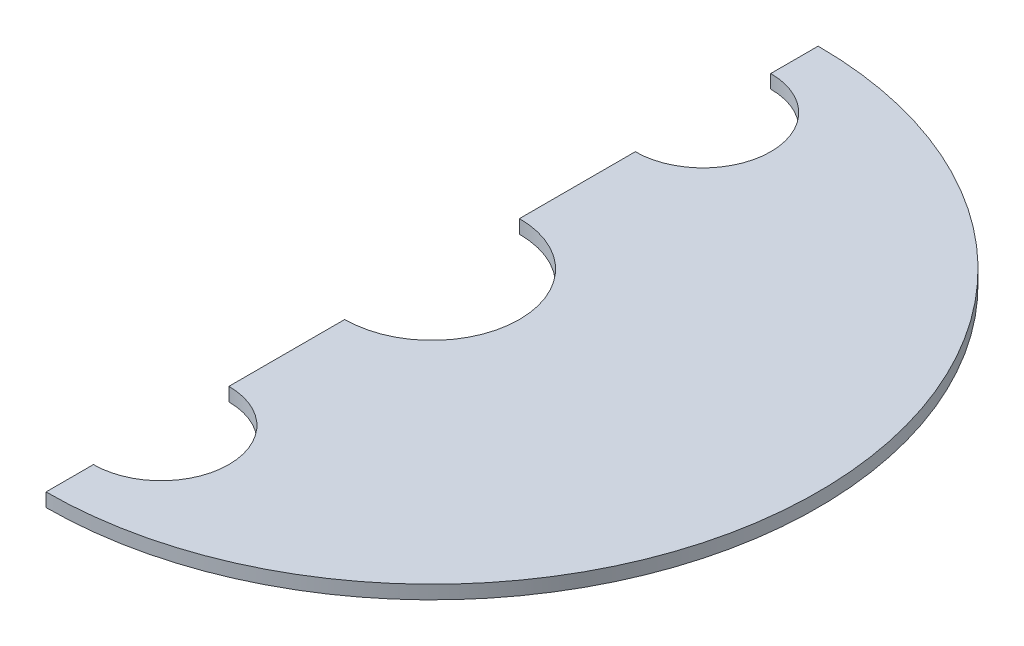
from build123d import *

# Parameters (mm, degrees)
BOSS_EXTRUDE1_DEPTH = 1


with BuildPart() as part:
    # Sketch1 → Boss-Extrude1 (new body)
    with BuildSketch(Plane(origin=(0, 0, 0), x_dir=(1, 0, 0), z_dir=(0, 1, 0))):
        with BuildLine():
            Line((0, 6.45), (0, 15))
            ThreePointArc((0, 15), (5, 20), (0, 25))
            Line((0, 25), (0, 28.5))
            ThreePointArc((0, 28.5), (28.5, 0), (0, -28.5))
            Line((0, -28.5), (0, -25))
            ThreePointArc((0, -25), (5, -20), (0, -15))
            Line((0, -15), (0, -6.45))
            ThreePointArc((0, -6.45), (6.45, 0), (0, 6.45))
        make_face()
    extrude(amount=BOSS_EXTRUDE1_DEPTH)


solid = part.part
